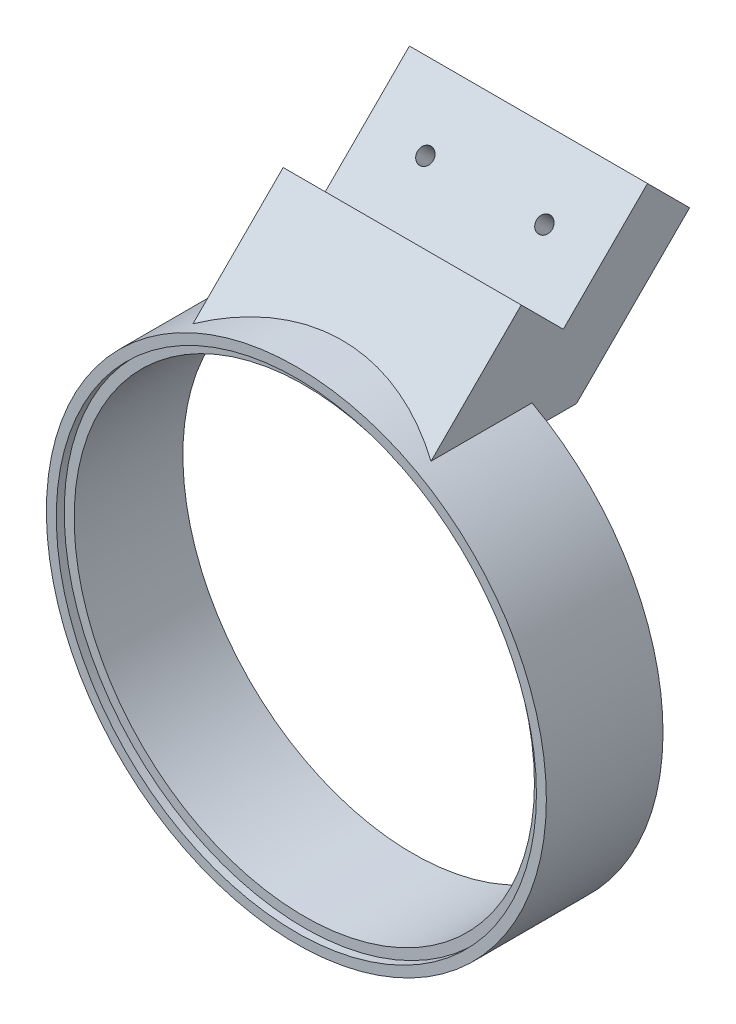
from build123d import *

# Parameters (mm, degrees)
SKETCH1_R                  = 63
SKETCH1_R_2                = 58
BOSS_EXTRUDE1_DEPTH        = 29.4
SKETCH2_R                  = 60.5
SKETCH2_R_2                = 58
CUT_EXTRUDE1_DEPTH         = 2
BOSS_EXTRUDE2_REACH        = 115.821
BOSS_EXTRUDE2_START_RADIUS = 63
BOSS_EXTRUDE2_END_RADIUS   = 63
SKETCH3_W                  = 60
SKETCH3_H                  = 29.4
SKETCH5_W                  = 29.4
SKETCH5_H                  = 24.463774017
CUT_EXTRUDE2_DEPTH         = 60
BOSS_EXTRUDE3_DEPTH        = 60
SKETCH7_W                  = 60
SKETCH7_H                  = 41.577878734
BOSS_EXTRUDE4_DEPTH        = 50
CUT_EXTRUDE3_REACH         = 173.878
SKETCH9_W                  = 60
SKETCH9_H                  = 50
BOSS_EXTRUDE5_DEPTH        = 26.14
SKETCH10_W                 = 60
SKETCH10_H                 = 26.14
BOSS_EXTRUDE6_DEPTH        = 30
SKETCH11_R                 = 58
CUT_EXTRUDE4_DEPTH         = 168.932327916
SKETCH14_W                 = 60
SKETCH14_H                 = 55.370879129
CUT_EXTRUDE5_DEPTH         = 14.7
CUT_EXTRUDE6_REACH         = 171.856
BOSS_EXTRUDE7_DEPTH        = 60
SKETCH17_R                 = 58
CUT_EXTRUDE7_DEPTH         = 155.195379415
SKETCH18_W                 = 60
SKETCH18_H                 = 15
CUT_EXTRUDE8_DEPTH         = 50
SKETCH19_R                 = 2
CUT_EXTRUDE9_DEPTH         = 15
SKETCH20_W                 = 60
SKETCH20_H                 = 20
CUT_EXTRUDE10_DEPTH        = 140.943357594


with BuildPart() as part:
    # Sketch1 → Boss-Extrude1 (new body)
    with BuildSketch(Plane.XY):
        Circle(SKETCH1_R)
        Circle(SKETCH1_R_2, mode=Mode.SUBTRACT)
    extrude(amount=BOSS_EXTRUDE1_DEPTH)

    # Sketch2 → Cut-Extrude1 (cut)
    with BuildSketch(Plane.XY.offset(29.4)):
        Circle(SKETCH2_R)
        Circle(SKETCH2_R_2, mode=Mode.SUBTRACT)
    extrude(amount=-CUT_EXTRUDE1_DEPTH, mode=Mode.SUBTRACT)

    # Boss-Extrude2: from a cylinder face, 115.821 long prism both ways, kept between that surface and its translate by the depth
    boss_extrude2_start = Plane(origin=(0, 0, 14.7), z_dir=(0, 0, -1)) * Cylinder(BOSS_EXTRUDE2_START_RADIUS, 358.642, mode=Mode.PRIVATE)
    boss_extrude2_end = Plane(origin=(0, 20, 14.7), z_dir=(0, 0, -1)) * Cylinder(BOSS_EXTRUDE2_END_RADIUS, 358.642, mode=Mode.PRIVATE)
    # Sketch3 → Boss-Extrude2 (add, from a surface)
    with BuildSketch(Plane(origin=(0, 0, 0), x_dir=(1, 0, 0), z_dir=(0, 1, 0)), mode=Mode.PRIVATE) as boss_extrude2_sk1:
        with Locations((0, -14.7)):
            Rectangle(SKETCH3_W, SKETCH3_H)
    boss_extrude2_tool1 = extrude(boss_extrude2_sk1.sketch, amount=BOSS_EXTRUDE2_REACH, both=True, mode=Mode.PRIVATE)
    add(((boss_extrude2_tool1 - boss_extrude2_start) & boss_extrude2_end).solids().sort_by_distance((0, 65.398556, 14.7))[0])

    # Sketch5 → Cut-Extrude2 (cut)
    with BuildSketch(Plane.ZY.offset(30)):
        with Locations((14.7, 87.630442947)):
            Rectangle(SKETCH5_W, SKETCH5_H)
    extrude(amount=-CUT_EXTRUDE2_DEPTH, mode=Mode.SUBTRACT)

    # Sketch6 → Boss-Extrude3 (add)
    with BuildSketch(Plane.ZY.offset(30)):
        Polygon((0, 75.398555938), (29.4, 104.798555938), (29.4, 75.398555938), align=None)
    extrude(amount=-BOSS_EXTRUDE3_DEPTH)

    # Sketch7 → Boss-Extrude4 (add)
    with BuildSketch(Plane(origin=(0, 37.699277969, -37.699277969), x_dir=(1, 0, 0), z_dir=(0, 0.7071067811865513, -0.7071067811865438))):
        with Locations((0, -74.103769562)):
            Rectangle(SKETCH7_W, SKETCH7_H)
    extrude(amount=BOSS_EXTRUDE4_DEPTH)

    # Sketch8 → Cut-Extrude3 (cut, up to next)
    with BuildSketch(Plane(origin=(30, 0, 0), x_dir=(0, 0, -1), z_dir=(1, 0, 0)), mode=Mode.PRIVATE) as cut_extrude3_sk1:
        Polygon((14.566399692, 131.542834364), (-29.4, 87.576434672), (-29.4, 104.798555938), (5.955339059, 140.153894997), align=None)
    cut_extrude3_tool1 = extrude(cut_extrude3_sk1.sketch, amount=-CUT_EXTRUDE3_REACH, mode=Mode.PRIVATE) & part.part
    add(cut_extrude3_tool1.solids().sort_by_distance((30, 115.784229, 9.491665))[0], mode=Mode.SUBTRACT)

    # Sketch9 → Boss-Extrude5 (add)
    with BuildSketch(Plane(origin=(0, 37.699277969, 37.699277969), x_dir=(1, 0, 0), z_dir=(0, -0.7071067811865438, -0.7071067811865512))):
        with Locations((0, -78.314830195)):
            Rectangle(SKETCH9_W, SKETCH9_H)
    extrude(amount=BOSS_EXTRUDE5_DEPTH)

    # Sketch10 → Boss-Extrude6 (add)
    with BuildSketch(Plane(origin=(0, 37.699277969, -37.699277969), x_dir=(1, 0, 0), z_dir=(0, -0.7071067811865511, 0.707106781186544))):
        with Locations((0, 40.244830195)):
            Rectangle(SKETCH10_W, SKETCH10_H)
    extrude(amount=BOSS_EXTRUDE6_DEPTH)

    # Sketch11 → Cut-Extrude4 (cut, through all)
    with BuildSketch(Plane.XY.offset(29.4)):
        with Locations(Location((0, 0, 0), (0, 0, 121.147389922))):
            Circle(SKETCH11_R)
    extrude(amount=-CUT_EXTRUDE4_DEPTH, mode=Mode.SUBTRACT)

    # Sketch14 → Cut-Extrude5 (cut)
    with BuildSketch(Plane.XY.offset(29.4)):
        with Locations((0, 115.261874237)):
            Rectangle(SKETCH14_W, SKETCH14_H)
        with BuildLine():
            ThreePointArc((30, 55.398555938), (0, 63), (-30, 55.398555938))
            Line((-30, 55.398555938), (-30, 87.576434672))
            Line((-30, 87.576434672), (30, 87.576434672))
            Line((30, 87.576434672), (30, 55.398555938))
        make_face()
    extrude(amount=-CUT_EXTRUDE5_DEPTH, mode=Mode.SUBTRACT)

    # Sketch15 → Cut-Extrude6 (cut, up to next)
    with BuildSketch(Plane(origin=(30, 0, 0), x_dir=(0, 0, -1), z_dir=(1, 0, 0)), mode=Mode.PRIVATE) as cut_extrude6_sk1:
        Polygon((32.625906884, 113.483327173), (-14.7, 66.157420289), (-14.7, 102.276434672), (14.566399692, 131.542834364), align=None)
    cut_extrude6_tool1 = extrude(cut_extrude6_sk1.sketch, amount=-CUT_EXTRUDE6_REACH, mode=Mode.PRIVATE) & part.part
    add(cut_extrude6_tool1.solids().sort_by_distance((30, 102.300453, -4.802927))[0], mode=Mode.SUBTRACT)

    # Sketch16 → Boss-Extrude7 (add)
    with BuildSketch(Plane(origin=(30, 0, 0), x_dir=(0, 0, -1), z_dir=(1, 0, 0))):
        Polygon((-14.7, 66.157420289), (-25.458864351, 55.398555938), (-14.7, 55.398555938), align=None)
    extrude(amount=-BOSS_EXTRUDE7_DEPTH)

    # Sketch17 → Cut-Extrude7 (cut, through all)
    with BuildSketch(Plane.XY.offset(29.4)):
        with Locations(Location((0, 0, 0), (0, 0, 121.147389922))):
            Circle(SKETCH17_R)
    extrude(amount=-CUT_EXTRUDE7_DEPTH, mode=Mode.SUBTRACT)

    # Sketch18 → Cut-Extrude8 (cut)
    with BuildSketch(Plane(origin=(0, 73.054617028, -73.054617028), x_dir=(1, 0, 0), z_dir=(0, 0.7071067811865512, -0.7071067811865438))):
        with Locations((0, -49.674830195)):
            Rectangle(SKETCH18_W, SKETCH18_H)
    extrude(amount=-CUT_EXTRUDE8_DEPTH, mode=Mode.SUBTRACT)

    # Sketch19 → Cut-Extrude9 (cut)
    with BuildSketch(Plane(origin=(0, 19.215506709, 19.215506709), x_dir=(1, 0, 0), z_dir=(0, -0.7071067811865438, -0.7071067811865512))):
        with Locations(Location((15, -67.788834976, 0), (0, 0, 270))):
            Circle(SKETCH19_R)
        with Locations(Location((-15, -67.788834976, 0), (0, 0, 270))):
            Circle(SKETCH19_R)
    extrude(amount=-CUT_EXTRUDE9_DEPTH, mode=Mode.SUBTRACT)

    # Sketch20 → Cut-Extrude10 (cut, through all)
    with BuildSketch(Plane(origin=(0, 29.822108427, 29.822108427), x_dir=(1, 0, 0), z_dir=(0, 0.7071067811865438, 0.7071067811865513))):
        with Locations((0, 93.314830195)):
            Rectangle(SKETCH20_W, SKETCH20_H)
    extrude(amount=-CUT_EXTRUDE10_DEPTH, mode=Mode.SUBTRACT)


solid = part.part
